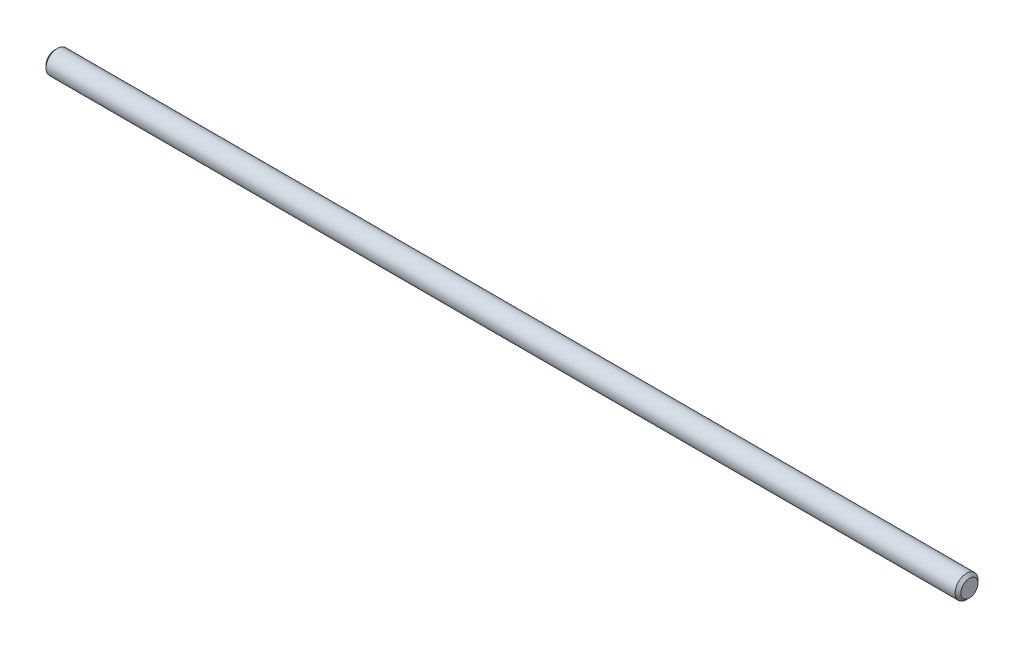
from build123d import *

# Parameters (mm, degrees)
SKETCH2_R           = 2
BOSS_EXTRUDE2_DEPTH = 160
CHAMFER2_SIZE       = 0.5


with BuildPart() as part:
    # Sketch2 → Boss-Extrude2 (new body)
    with BuildSketch(Plane(origin=(0, 0, 0), x_dir=(0, 0, -1), z_dir=(1, 0, 0))):
        Circle(SKETCH2_R)
    extrude(amount=BOSS_EXTRUDE2_DEPTH)

    # Chamfer2
    chamfer2_edges = [part.edges().sort_by_distance(p)[0] for p in [
        (0, 0, 2),
        (160, 0, 2),
    ]]
    chamfer(chamfer2_edges, length=CHAMFER2_SIZE)


solid = part.part
